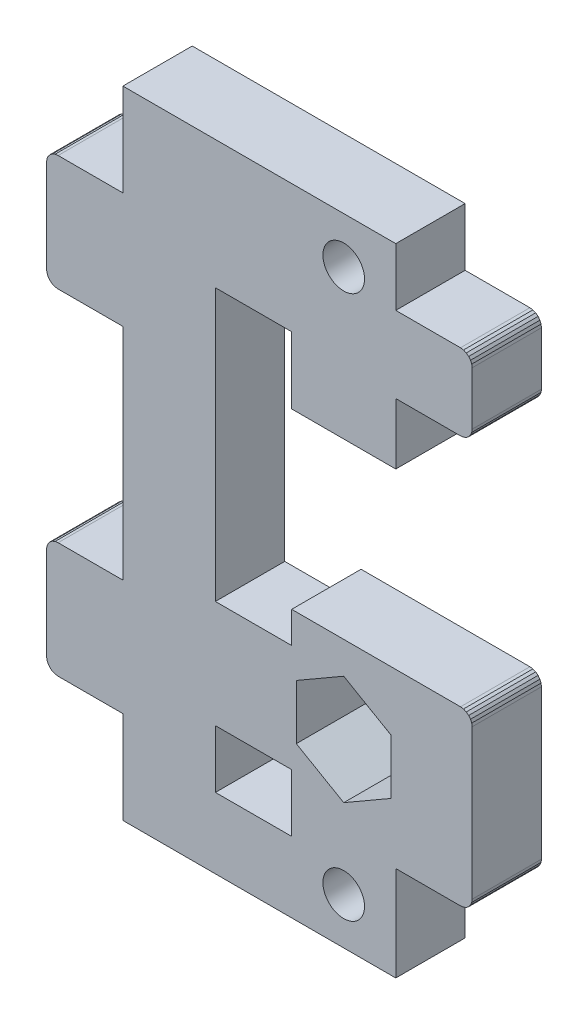
from build123d import *

# Parameters (mm, degrees)
MODEL_R                  = 1.8
RESSALTO_EXTRUS_O1_DEPTH = 6


with BuildPart() as part:
    # Model → Ressalto-extrusão1 (new body)
    with BuildSketch(Plane.XY):
        Polygon((65.723755116, 35.074422304), (65.623854693, 35.315603259), (65.46493607, 35.52271004), (65.257829289, 35.681628662), (65.016648334, 35.781529085), (64.757829289, 35.815603259), (50.157829289, 35.815603259), (50.157829289, 33.103327835), (43.557829289, 33.103327835), (43.557829289, 56.603327835), (50.157829289, 56.603327835), (50.157829289, 50.820791423), (59.157829289, 50.820791423), (59.157829289, 56.103327835), (64.757829289, 56.103327835), (65.016648334, 56.137402008), (65.257829289, 56.237302431), (65.46493607, 56.396221053), (65.623854693, 56.603327835), (65.723755116, 56.844508789), (65.757829289, 57.103327835), (65.757829289, 61.703327835), (65.723755116, 61.96214688), (65.623854693, 62.203327835), (65.46493607, 62.410434616), (65.257829289, 62.569353238), (65.016648334, 62.669253661), (64.757829289, 62.703327835), (59.157829289, 62.703327835), (59.157829289, 67.703327835), (35.557829289, 67.703327835), (35.557829289, 59.703327835), (29.957829289, 59.703327835), (29.699010244, 59.669253661), (29.457829289, 59.569353238), (29.250722508, 59.410434616), (29.091803885, 59.203327835), (28.991903463, 58.96214688), (28.957829289, 58.703327835), (28.957829289, 50.703327835), (28.991903463, 50.444508789), (29.091803885, 50.203327835), (29.250722508, 49.996221053), (29.457829289, 49.837302431), (29.699010244, 49.737402008), (29.957829289, 49.703327835), (35.557829289, 49.703327835), (35.557829289, 30.703327835), (29.957829289, 30.703327835), (29.699010244, 30.669253661), (29.457829289, 30.569353238), (29.250722508, 30.410434616), (29.091803885, 30.203327835), (28.991903463, 29.96214688), (28.957829289, 29.703327835), (28.957829289, 21.703327835), (28.991903463, 21.444508789), (29.091803885, 21.203327835), (29.250722508, 20.996221053), (29.457829289, 20.837302431), (29.699010244, 20.737402008), (29.957829289, 20.703327835), (35.557829289, 20.703327835), (35.557829289, 12.703327835), (59.157829289, 12.703327835), (59.157829289, 20.903327835), (64.757829289, 20.903327835), (65.016648334, 20.937402008), (65.257829289, 21.037302431), (65.46493607, 21.196221053), (65.623854693, 21.403327835), (65.723755116, 21.644508789), (65.757829289, 21.903327835), (65.757829289, 34.815603259), align=None)
        with Locations((54.657829289, 63.703327835)):
            Circle(MODEL_R, mode=Mode.SUBTRACT)
        with Locations((54.657829289, 16.703327835)):
            Circle(MODEL_R, mode=Mode.SUBTRACT)
        Polygon((43.557829289, 23.803327835), (43.561764571, 18.803329383), (50.161762529, 18.808521259), (50.157829289, 23.808519712), align=None, mode=Mode.SUBTRACT)
        Polygon((50.557829289, 30.687927527), (50.557829289, 25.95365532), (54.657829289, 23.586519216), (58.757829289, 25.95365532), (58.757829289, 30.687927527), (54.657829289, 33.055063631), align=None, mode=Mode.SUBTRACT)
    extrude(amount=RESSALTO_EXTRUS_O1_DEPTH)


solid = part.part
